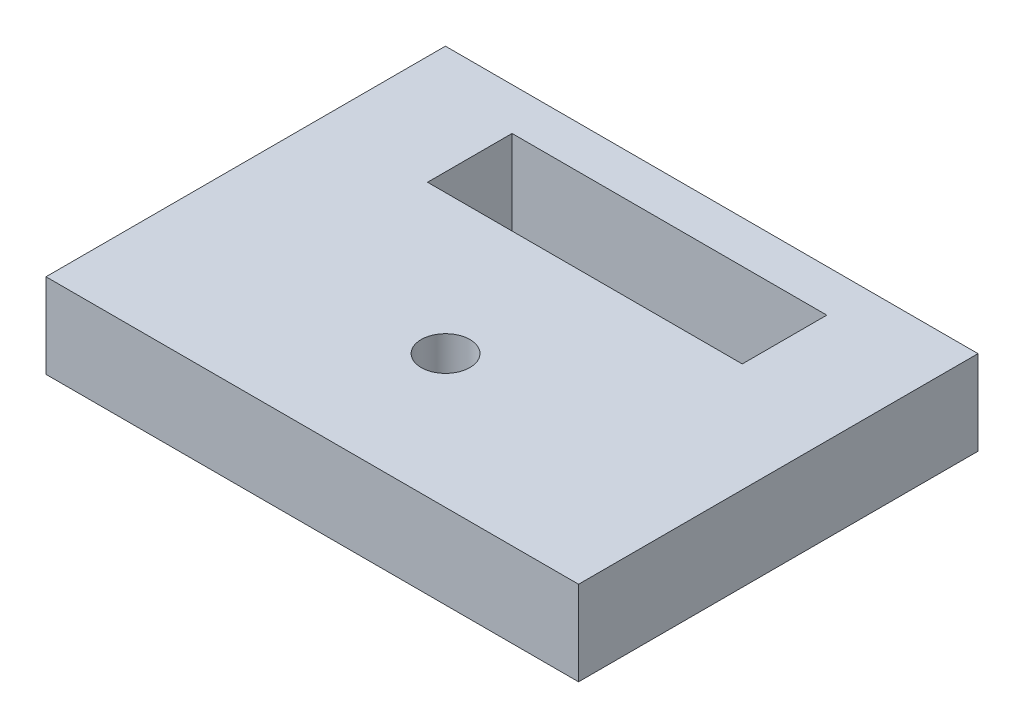
from build123d import *

# Parameters (mm, degrees)
SKETCH1_W             = 40
SKETCH1_H             = 30
BOSS_EXTRUDE1_DEPTH   = 6.35
SKETCH2_W             = 23.64
SKETCH2_H             = 6.35
CUT_EXTRUDE1_DEPTH    = 7.35
F_6_CLEARANCE_HOLE1_D = 3.6576


with BuildPart() as part:
    # Sketch1 → Boss-Extrude1 (new body)
    with BuildSketch(Plane(origin=(0, 0, 0), x_dir=(1, 0, 0), z_dir=(0, 1, 0))):
        Rectangle(SKETCH1_W, SKETCH1_H)
    extrude(amount=BOSS_EXTRUDE1_DEPTH)

    # Sketch2 → Cut-Extrude1 (cut, through all)
    with BuildSketch(Plane(origin=(0, 6.35, 0), x_dir=(1, 0, 0), z_dir=(0, 1, 0))):
        with Locations((0, 8.65)):
            Rectangle(SKETCH2_W, SKETCH2_H)
    extrude(amount=-CUT_EXTRUDE1_DEPTH, mode=Mode.SUBTRACT)

    # #6 Clearance Hole1 (through all)
    with Locations(Plane(origin=(0, 6.35, 0), x_dir=(1, 0, 0), z_dir=(0, 1, 0))):
        with Locations((0, -4.9898)):
            Hole(F_6_CLEARANCE_HOLE1_D / 2)


solid = part.part
